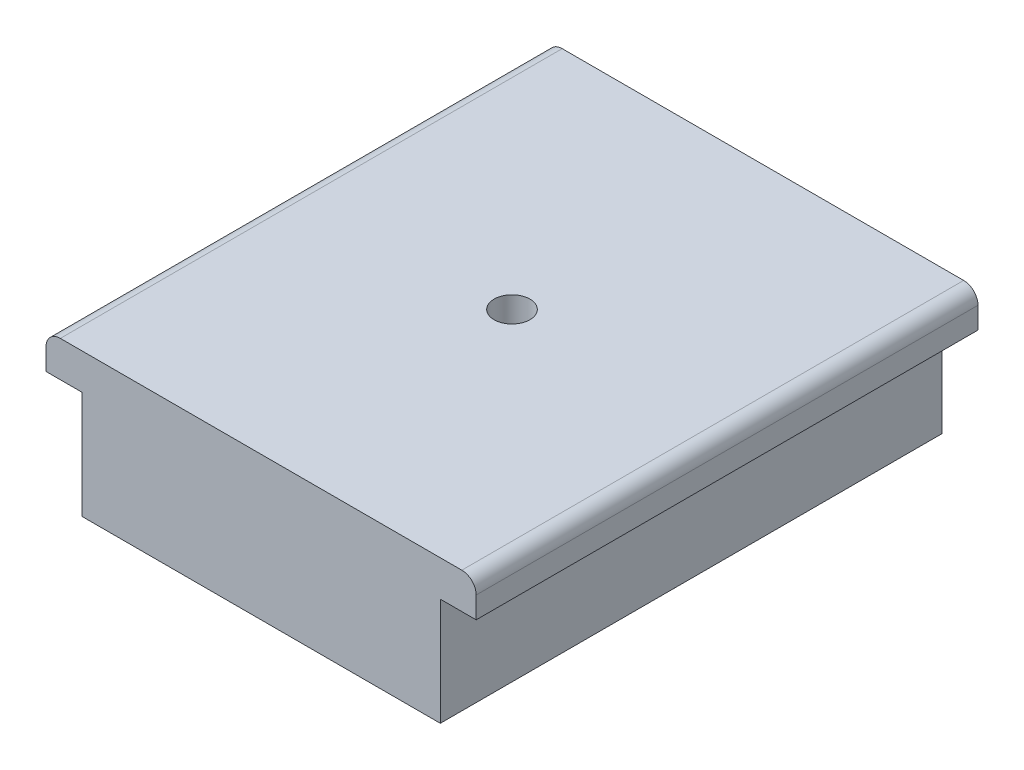
from build123d import *

# Parameters (mm, degrees)
SKETCH1_W               = 50
SKETCH1_H               = 15
BOSS_EXTRUDE1_DEPTH     = 35
SKETCH3_W               = 60
SKETCH3_H               = 70
BOSS_EXTRUDE2_DEPTH     = 5
SKETCH2_R               = 2.5
CUT_EXTRUDE1_DEPTH      = 1
CUT_EXTRUDE1_DEPTH_BACK = 10
FILLET1_R               = 2


with BuildPart() as part:
    # Sketch1 → Boss-Extrude1 (new body, symmetric)
    with BuildSketch(Plane.XY):
        Rectangle(SKETCH1_W, SKETCH1_H)
    extrude(amount=BOSS_EXTRUDE1_DEPTH, both=True)

    # Sketch3 → Boss-Extrude2 (add)
    with BuildSketch(Plane(origin=(0, 7.5, 0), x_dir=(1, 0, 0), z_dir=(0, 1, 0))):
        Rectangle(SKETCH3_W, SKETCH3_H)
    extrude(amount=BOSS_EXTRUDE2_DEPTH)

    # Sketch2 → Cut-Extrude1 (cut, two sides)
    with BuildSketch(Plane(origin=(0, 12.5, 0), x_dir=(1, 0, 0), z_dir=(0, 1, 0))) as cut_extrude1_sk:
        Circle(SKETCH2_R)
    extrude(amount=CUT_EXTRUDE1_DEPTH, mode=Mode.SUBTRACT)
    extrude(cut_extrude1_sk.sketch, amount=-CUT_EXTRUDE1_DEPTH_BACK, mode=Mode.SUBTRACT)

    # Fillet1
    fillet1_edges = [part.edges().sort_by_distance(p)[0] for p in [
        (-30, 12.5, 0),
        (30, 12.5, 0),
    ]]
    fillet(fillet1_edges, radius=FILLET1_R)


solid = part.part
